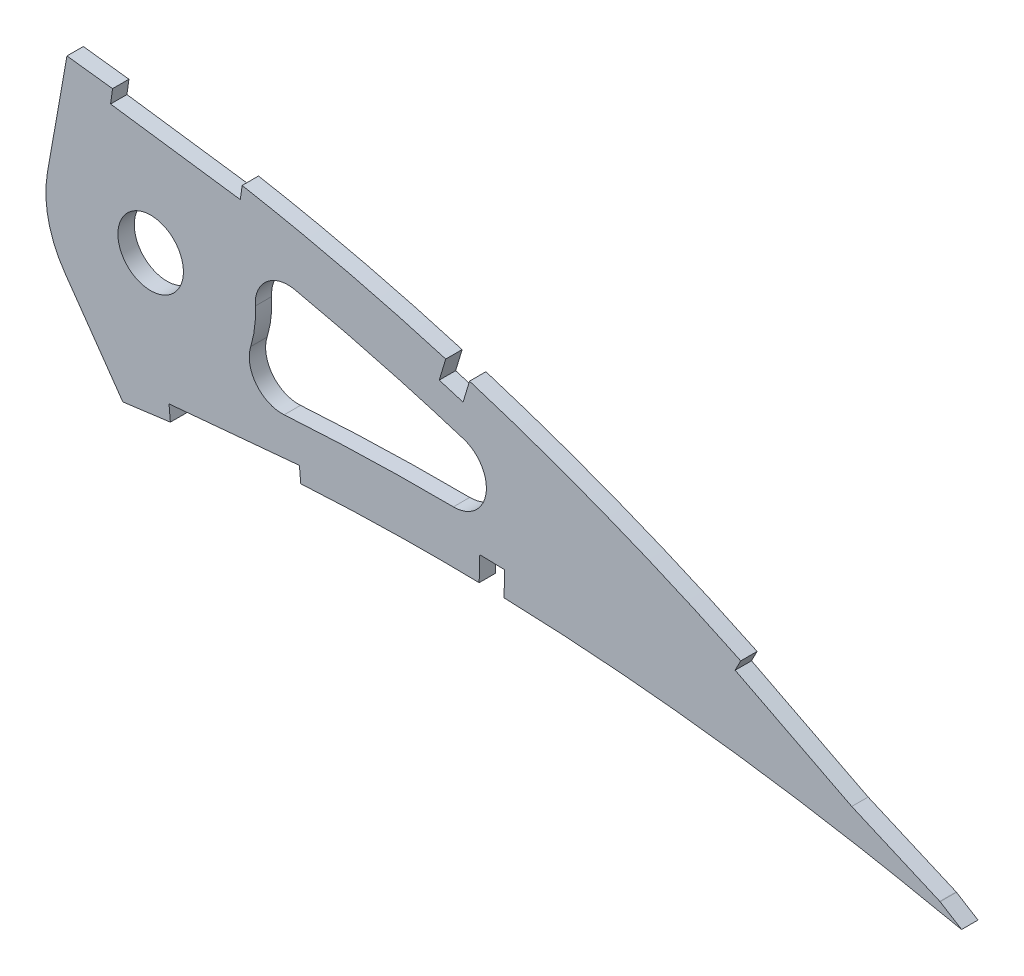
from build123d import *

# Parameters (mm, degrees)
BOSS_EXTRUDE1_DEPTH = 3.175
CUT_EXTRUDE3_DEPTH  = 4.1750001
CUT_EXTRUDE4_DEPTH  = 7.62
FILLET1_R           = 6.35


with BuildPart() as part:
    # Sketch1 → Boss-Extrude1 (new body)
    with BuildSketch(Plane.XY):
        with BuildLine():
            Line((519.580178516, -0.811051185), (524.404942797, -1.768650656))
            Line((524.404942797, -1.768650656), (520.229019484, 0.811051185))
            add(Edge.make_bspline(
                [(520.229019484, 0.811051185), (520.189166605, 0.835670541), (520.029909792, 0.934052399), (519.671075297, 1.154156729), (519.073541109, 1.52075127), (518.237045599, 2.031290225), (517.162238007, 2.684417324), (515.848577801, 3.475559373), (514.296885216, 4.402146321), (512.507535633, 5.459795421), (510.480712337, 6.64355473), (508.21718701, 7.948628257), (505.717156954, 9.367627965), (502.981590452, 10.894755239), (500.011426026, 12.522747531), (496.807225449, 14.244251548), (493.37013628, 16.050511122), (489.701477824, 17.933756977), (485.801919013, 19.88358962), (481.673298347, 21.891894303), (477.316991217, 23.948657398), (472.734484625, 26.042905917), (467.928411224, 28.166102482), (462.900099753, 30.30504754), (457.652415647, 32.45047346), (452.187593096, 34.590170691), (446.508867721, 36.714394111), (440.618430338, 38.809382682), (434.52068427, 40.865980983), (428.218587641, 42.870829), (421.71664718, 44.813038248), (415.018640596, 46.680016502), (408.130151416, 48.4621889), (401.05554842, 50.146576673), (393.800827801, 51.721905645), (386.37175624, 53.178690862), (378.7745642, 54.502388693), (371.03030434, 55.691966852), (363.263579962, 56.681494561), (355.512835044, 57.651994424), (347.773632806, 58.563690257), (339.939841334, 59.436765181), (332.018997168, 60.266303487), (324.018957152, 61.049711288), (315.947820171, 61.783607472), (307.813973652, 62.465839869), (299.625288266, 63.092542591), (291.390398495, 63.662750235), (283.117445562, 64.171449818), (274.815241205, 64.618259557), (266.492213302, 65.000063177), (258.157023363, 65.314229919), (249.818522106, 65.558863312), (241.485365181, 65.731619671), (233.166575282, 65.831412809), (224.870805251, 65.855515939), (216.607073574, 65.803497941), (208.384033719, 65.673572684), (200.210713382, 65.463961556), (192.095777843, 65.174273359), (184.048002143, 64.804633746), (176.076197788, 64.351947189), (168.189012741, 63.819098613), (160.39523005, 63.203849575), (152.703412853, 62.5060365), (145.121622257, 61.728568125), (137.65829938, 60.86932984), (130.321442651, 59.930766435), (123.119077117, 58.914718085), (116.059284027, 57.820631377), (109.149625996, 56.651666482), (102.397560522, 55.409019412), (95.81023125, 54.096333304), (89.394810054, 52.713950514), (83.158087983, 51.266017865), (77.106546628, 49.75505799), (71.246691254, 48.18383703), (65.58446207, 46.556125144), (60.125584795, 44.875615234), (54.876423204, 43.144153764), (49.840944503, 41.368305654), (45.025334256, 39.549331576), (40.433281375, 37.692835265), (36.070167381, 35.80135162), (31.939251719, 33.880646801), (28.045209615, 31.932907511), (24.39081638, 29.963590665), (20.979740738, 27.975715944), (17.815266227, 25.972975661), (14.898722839, 23.96044987), (12.234131686, 21.939401784), (9.822408113, 19.914938493), (7.665078309, 17.890142748), (5.765226023, 15.866409302), (4.122782784, 13.847302025), (2.739901149, 11.834419923), (1.61682102, 9.829667672), (0.75608259, 7.834501578), (0.156832386, 5.85004365), (-0.171193188, 3.879222922), (-0.252840734, 1.920459398), (-0.084154315, 0.639196632), (0, 0)],
                knots=[0, 0, 0, 0, 0.00025409, 0.001015373, 0.002283359, 0.004056577, 0.006330982, 0.009105275, 0.012374489, 0.016134023, 0.02037966, 0.025105976, 0.030306237, 0.035972206, 0.042099522, 0.048678064, 0.055701664, 0.063160184, 0.071045824, 0.079349826, 0.08806291, 0.097175757, 0.106678112, 0.116561573, 0.126814276, 0.1374283, 0.148393618, 0.15969976, 0.171338126, 0.183297699, 0.195569604, 0.208143556, 0.221011593, 0.234161831, 0.24758745, 0.261276822, 0.27522271, 0.289414144, 0.3037712, 0.317689227, 0.331784111, 0.346039677, 0.36044387, 0.374982721, 0.389640455, 0.404403317, 0.419256601, 0.434186749, 0.449177265, 0.464214782, 0.479284009, 0.49436974, 0.509457833, 0.524532346, 0.53957932, 0.554582984, 0.569529546, 0.584403417, 0.599190992, 0.613876838, 0.628447475, 0.642888675, 0.657186054, 0.671325546, 0.685294014, 0.699078147, 0.712665095, 0.726042645, 0.739197713, 0.752117586, 0.764792042, 0.777208152, 0.789355685, 0.80122396, 0.812803686, 0.824082909, 0.835054602, 0.845709571, 0.856037853, 0.866033834, 0.875688843, 0.884997719, 0.893953426, 0.902552897, 0.910789386, 0.918660734, 0.926166253, 0.933302626, 0.94007122, 0.94647478, 0.952517526, 0.958204819, 0.963546652, 0.9685566, 0.973249913, 0.977651041, 0.981787043, 0.985694226, 0.989415109, 0.993001157, 0.996508416, 1, 1, 1, 1], degree=3))
            add(Edge.make_bspline(
                [(0, 0), (0.133592971, -0.630647919), (0.401392883, -1.8948421), (1.12897029, -3.714757932), (2.091156676, -5.464224213), (3.308146123, -7.138593951), (4.771846833, -8.737409521), (6.479026026, -10.262333902), (8.42800953, -11.712547121), (10.616246406, -13.087389262), (13.040557967, -14.388319695), (15.69821927, -15.614529628), (18.58680706, -16.765635887), (21.703174164, -17.840099654), (25.043510698, -18.839557444), (28.604640883, -19.761573512), (32.382515332, -20.607436647), (36.373500457, -21.374987622), (40.573247311, -22.065006311), (44.977392966, -22.677106427), (49.581416855, -23.211670923), (54.380802091, -23.667578066), (59.370801609, -24.045808466), (64.546441805, -24.346612989), (69.902698778, -24.570945614), (75.434441794, -24.717953346), (81.136253147, -24.789928223), (87.002979994, -24.787950681), (93.028883282, -24.711491768), (99.208815464, -24.564775433), (105.536846201, -24.346872236), (112.007262561, -24.060419153), (118.614228145, -23.708298892), (125.351817225, -23.291705179), (132.214100493, -22.812484346), (139.195119589, -22.274479418), (146.288532921, -21.679032497), (153.488154076, -21.029614162), (160.787609185, -20.329475604), (168.180591644, -19.580832593), (175.660575836, -18.787206853), (183.220899465, -17.951170059), (190.855131019, -17.077182461), (198.556296664, -16.166825422), (206.317884213, -15.225296547), (214.132591981, -14.254394805), (221.993885293, -13.257859815), (229.894693671, -12.240383742), (237.827620604, -11.201850487), (245.785993956, -10.149659277), (253.762138918, -9.082943465), (261.749112783, -8.007189221), (269.739522148, -6.925740253), (277.725584215, -5.838929488), (285.70027901, -4.751260828), (293.656208576, -3.665720235), (301.585579958, -2.582406874), (309.481219182, -1.506705212), (317.335175518, -0.438483792), (325.140206955, 0.620091626), (332.888833934, 1.665861231), (340.573746099, 2.697505345), (348.187015915, 3.714371056), (355.720983847, 4.716840325), (363.055280122, 5.674485749), (370.170740115, 6.638302095), (377.091341637, 7.428417974), (383.925772848, 8.102810237), (390.681133097, 8.655718896), (397.349310673, 9.095098533), (403.922665289, 9.424088714), (410.393362863, 9.647282626), (416.753229966, 9.771301523), (422.994322965, 9.799292754), (429.108122993, 9.740182902), (435.086678505, 9.598736647), (440.921645401, 9.381302955), (446.604883368, 9.095217537), (452.128319892, 8.748279397), (457.483662622, 8.34560601), (462.663449177, 7.896598156), (467.65968785, 7.407828642), (472.464706853, 6.884881883), (477.071494939, 6.338715544), (481.472678479, 5.77292572), (485.661637464, 5.196810252), (489.631628754, 4.616207627), (493.376364947, 4.038530197), (496.889962423, 3.469289139), (500.16674573, 2.91603967), (503.201581909, 2.38395084), (505.989204715, 1.878219093), (508.525746868, 1.40522509), (510.806198597, 0.967318665), (512.827510034, 0.571716412), (514.585922757, 0.220164109), (516.078859088, -0.082385429), (517.303711765, -0.334738039), (518.258620558, -0.532751237), (518.941699265, -0.676741413), (519.352209069, -0.762422848), (519.534603778, -0.801329602), (519.580178516, -0.811051185)],
                knots=[0, 0, 0, 0, 0.003638255, 0.007293231, 0.011028136, 0.014901081, 0.018963272, 0.023258475, 0.027820626, 0.032679082, 0.03785316, 0.043361875, 0.049214679, 0.055422346, 0.061988786, 0.068918036, 0.076211157, 0.083868392, 0.091887411, 0.100265912, 0.108999867, 0.118084529, 0.127514843, 0.13728527, 0.147387917, 0.157816481, 0.168563473, 0.179619128, 0.190977373, 0.202626974, 0.214560478, 0.226767249, 0.239236417, 0.251959004, 0.264923894, 0.278119703, 0.291536035, 0.30516028, 0.318980685, 0.332985499, 0.34716279, 0.361498603, 0.375980747, 0.390597192, 0.405332593, 0.420174823, 0.435109533, 0.450124276, 0.465203068, 0.480333154, 0.495500583, 0.510689775, 0.525887334, 0.541078314, 0.556247233, 0.571381784, 0.586466041, 0.601484516, 0.616424329, 0.631269422, 0.646006524, 0.660620684, 0.675098188, 0.689422858, 0.703581825, 0.716907564, 0.730009274, 0.742952128, 0.755725558, 0.768319952, 0.780724337, 0.792926529, 0.804916041, 0.816679084, 0.828203524, 0.8394749, 0.850481359, 0.861207697, 0.871639326, 0.881763414, 0.891563605, 0.901027364, 0.910138977, 0.918883976, 0.927249278, 0.935221104, 0.942784739, 0.949928188, 0.956638464, 0.962904203, 0.968712287, 0.974054485, 0.978918432, 0.983297219, 0.987180246, 0.990560674, 0.993433357, 0.995790625, 0.997629587, 0.998945816, 0.999736592, 1, 1, 1, 1], degree=3))
        make_face()
    extrude(amount=BOSS_EXTRUDE1_DEPTH)

    # Sketch4 → Cut-Extrude3 (cut, through all)
    with BuildSketch(Plane(origin=(0, 0, 0), x_dir=(-1, 0, 0), z_dir=(0, 0, -1))):
        with BuildLine():
            Line((-349.142459993, 48.169188001), (-347.130907312, 36.761105856))
            ThreePointArc((-347.130907312, 36.761105856), (-346.899524588, 35.003579579), (-346.822200854, 33.232574886))
            ThreePointArc((-346.822200854, 33.232574886), (-347.762672414, 27.12223304), (-350.497031314, 21.577501699))
            Line((-350.497031314, 21.577501699), (-355.179611663, 14.890083907))
            add(Edge.make_bspline(
                [(-355.179611663, 14.890083907), (-354.634768183, 14.81838126), (-351.343111064, 14.384733115), (-345.317068282, 13.581422906), (-334.359007699, 12.116770486), (-315.178957353, 9.528809507), (-287.808238346, 5.789020446), (-254.983546479, 1.313075622), (-222.189540662, -3.034811338), (-189.410638648, -7.095853132), (-156.653979445, -10.650756055), (-129.381299848, -12.944898136), (-107.608324737, -14.148463497), (-91.320521139, -14.652053641), (-75.107437099, -14.647466184), (-61.710842675, -14.089664127), (-51.134134813, -13.189629084), (-43.306667964, -12.239557455), (-35.641142462, -10.958898329), (-28.237034853, -9.263609663), (-21.289211903, -7.058302801), (-16.203229259, -4.686643315), (-13.046062847, -2.547825054), (-11.605646483, -1.201001207), (-10.835951724, -0.222672899), (-10.520186588, 0.293626308), (-10.288606614, 0.769486043), (-10.205494123, 0.982386522), (-10.178508929, 1.064293938), (-10.15770337, 1.134911906), (-10.110488282, 1.322521107), (-10.064288932, 1.524878966), (-10.035416174, 1.656454651), (-10.021983668, 1.718504447)],
                knots=[0.309141937, 0.309141937, 0.309141937, 0.309141937, 0.312240805, 0.327852845, 0.343464885, 0.374688966, 0.437137127, 0.499585288, 0.562033448, 0.624481609, 0.68692977, 0.749377931, 0.780602012, 0.811826092, 0.843050173, 0.874274253, 0.889886293, 0.905498334, 0.921110374, 0.936722414, 0.952334454, 0.967946495, 0.975752515, 0.983558535, 0.987461545, 0.991364555, 0.99331606, 0.995267565, 0.996243318, 0.99721907, 0.998194823, 0.998682699, 0.999170575, 0.999170575, 0.999170575, 0.999170575], degree=3))
            add(Edge.make_bspline(
                [(-10.021983668, 1.718504447), (-10.013687856, 1.783768627), (-9.996445529, 1.922731887), (-9.972174442, 2.13380764), (-9.954758577, 2.326720127), (-9.95209276, 2.384964033), (-9.950305509, 2.48525297), (-9.961308657, 2.734439136), (-10.012167255, 3.144193433), (-10.083924075, 3.510172621), (-10.222387191, 4.033107903), (-10.617125097, 5.11754818), (-11.618419928, 6.925188316), (-14.102556964, 10.090723207), (-18.425636817, 14.053423759), (-24.652613537, 18.402785053), (-31.49228206, 22.339174543), (-38.727193503, 25.901322004), (-46.234469632, 29.135461005), (-56.507441507, 33.059973808), (-69.720706242, 37.323053539), (-85.944850414, 41.597783381), (-102.419374763, 45.156825801), (-124.627374805, 49.072607453), (-152.703767215, 52.587446016), (-186.671940606, 55.005427433), (-220.783980102, 55.888644379), (-254.954152119, 55.438562708), (-289.123377617, 53.797708511), (-317.566439881, 51.530591277), (-337.432329226, 49.501787715), (-346.070123739, 48.528859346), (-349.021979224, 48.183312846), (-349.142459993, 48.169188001)],
                knots=[0.000796283, 0.000796283, 0.000796283, 0.000796283, 0.001284176, 0.001772068, 0.002747853, 0.003723638, 0.004699423, 0.006650992, 0.008602562, 0.010554132, 0.012505702, 0.016408841, 0.02421512, 0.032021399, 0.047633957, 0.063246516, 0.078859074, 0.094471632, 0.11008419, 0.125696748, 0.156921864, 0.18814698, 0.219372096, 0.250597212, 0.313047445, 0.375497677, 0.437947909, 0.500398142, 0.562848374, 0.625298606, 0.656523722, 0.67213628, 0.672800692, 0.672800692, 0.672800692, 0.672800692], degree=3))
        make_face()
        with BuildLine():
            ThreePointArc((-360.792200854, 33.232574886), (-367.142200854, 39.582574886), (-373.492200854, 33.232574886))
            ThreePointArc((-373.492200854, 33.232574886), (-367.142200854, 26.882574886), (-360.792200854, 33.232574886))
        make_face()
        with BuildLine():
            Line((-350.909730833, 58.191878985), (-349.142459993, 48.169188001))
            add(Edge.make_bspline(
                [(-10.021983668, 1.718504447), (-10.013687856, 1.783768627), (-9.996445529, 1.922731887), (-9.972174442, 2.13380764), (-9.954758577, 2.326720127), (-9.95209276, 2.384964033), (-9.950305509, 2.48525297), (-9.961308657, 2.734439136), (-10.012167255, 3.144193433), (-10.083924075, 3.510172621), (-10.222387191, 4.033107903), (-10.617125097, 5.11754818), (-11.618419928, 6.925188316), (-14.102556964, 10.090723207), (-18.425636817, 14.053423759), (-24.652613537, 18.402785053), (-31.49228206, 22.339174543), (-38.727193503, 25.901322004), (-46.234469632, 29.135461005), (-56.507441507, 33.059973808), (-69.720706242, 37.323053539), (-85.944850414, 41.597783381), (-102.419374763, 45.156825801), (-124.627374805, 49.072607453), (-152.703767215, 52.587446016), (-186.671940606, 55.005427433), (-220.783980102, 55.888644379), (-254.954152119, 55.438562708), (-289.123377617, 53.797708511), (-317.566439881, 51.530591277), (-337.432329226, 49.501787715), (-346.070123739, 48.528859346), (-349.021979224, 48.183312846), (-349.142459993, 48.169188001)],
                knots=[0.000796283, 0.000796283, 0.000796283, 0.000796283, 0.001284176, 0.001772068, 0.002747853, 0.003723638, 0.004699423, 0.006650992, 0.008602562, 0.010554132, 0.012505702, 0.016408841, 0.02421512, 0.032021399, 0.047633957, 0.063246516, 0.078859074, 0.094471632, 0.11008419, 0.125696748, 0.156921864, 0.18814698, 0.219372096, 0.250597212, 0.313047445, 0.375497677, 0.437947909, 0.500398142, 0.562848374, 0.625298606, 0.656523722, 0.67213628, 0.672800692, 0.672800692, 0.672800692, 0.672800692], degree=3))
            add(Edge.make_bspline(
                [(-355.179611663, 14.890083907), (-354.634768183, 14.81838126), (-351.343111064, 14.384733115), (-345.317068282, 13.581422906), (-334.359007699, 12.116770486), (-315.178957353, 9.528809507), (-287.808238346, 5.789020446), (-254.983546479, 1.313075622), (-222.189540662, -3.034811338), (-189.410638648, -7.095853132), (-156.653979445, -10.650756055), (-129.381299848, -12.944898136), (-107.608324737, -14.148463497), (-91.320521139, -14.652053641), (-75.107437099, -14.647466184), (-61.710842675, -14.089664127), (-51.134134813, -13.189629084), (-43.306667964, -12.239557455), (-35.641142462, -10.958898329), (-28.237034853, -9.263609663), (-21.289211903, -7.058302801), (-16.203229259, -4.686643315), (-13.046062847, -2.547825054), (-11.605646483, -1.201001207), (-10.835951724, -0.222672899), (-10.520186588, 0.293626308), (-10.288606614, 0.769486043), (-10.205494123, 0.982386522), (-10.178508929, 1.064293938), (-10.15770337, 1.134911906), (-10.110488282, 1.322521107), (-10.064288932, 1.524878966), (-10.035416174, 1.656454651), (-10.021983668, 1.718504447)],
                knots=[0.309141937, 0.309141937, 0.309141937, 0.309141937, 0.312240805, 0.327852845, 0.343464885, 0.374688966, 0.437137127, 0.499585288, 0.562033448, 0.624481609, 0.68692977, 0.749377931, 0.780602012, 0.811826092, 0.843050173, 0.874274253, 0.889886293, 0.905498334, 0.921110374, 0.936722414, 0.952334454, 0.967946495, 0.975752515, 0.983558535, 0.987461545, 0.991364555, 0.99331606, 0.995267565, 0.996243318, 0.99721907, 0.998194823, 0.998682699, 0.999170575, 0.999170575, 0.999170575, 0.999170575], degree=3))
            Line((-355.179611663, 14.890083907), (-361.749554482, 5.507233166))
            add(Edge.make_bspline(
                [(-361.749554482, 5.507233166), (-359.750002253, 5.242796176), (-355.23730571, 4.652482144), (-348.187015915, 3.714371056), (-340.573746099, 2.697505345), (-332.888833934, 1.665861231), (-325.140206955, 0.620091626), (-317.335175518, -0.438483792), (-309.481219182, -1.506705212), (-301.585579958, -2.582406874), (-293.656208576, -3.665720235), (-285.70027901, -4.751260828), (-277.725584215, -5.838929488), (-269.739522148, -6.925740253), (-261.749112783, -8.007189221), (-253.762138918, -9.082943465), (-245.785993956, -10.149659277), (-237.827620604, -11.201850487), (-229.894693671, -12.240383742), (-221.993885293, -13.257859815), (-214.132591981, -14.254394805), (-206.317884213, -15.225296547), (-198.556296664, -16.166825422), (-190.855131019, -17.077182461), (-183.220899465, -17.951170059), (-175.660575836, -18.787206853), (-168.180591644, -19.580832593), (-160.787609185, -20.329475604), (-153.488154076, -21.029614162), (-146.288532921, -21.679032497), (-139.195119589, -22.274479418), (-132.214100493, -22.812484346), (-125.351817225, -23.291705179), (-118.614228145, -23.708298892), (-112.007262561, -24.060419153), (-105.536846201, -24.346872236), (-99.208815464, -24.564775433), (-93.028883282, -24.711491768), (-87.002979994, -24.787950681), (-81.136253147, -24.789928223), (-75.434441794, -24.717953346), (-69.902698778, -24.570945614), (-64.546441805, -24.346612989), (-59.370801609, -24.045808466), (-54.380802091, -23.667578066), (-49.581416855, -23.211670923), (-44.977392966, -22.677106427), (-40.573247311, -22.065006311), (-36.373500457, -21.374987622), (-32.382515332, -20.607436647), (-28.604640883, -19.761573512), (-25.043510698, -18.839557444), (-21.703174164, -17.840099654), (-18.58680706, -16.765635887), (-15.69821927, -15.614529628), (-13.040557967, -14.388319695), (-10.616246406, -13.087389262), (-8.42800953, -11.712547121), (-6.479026026, -10.262333902), (-4.771846833, -8.737409521), (-3.308146123, -7.138593951), (-2.091156676, -5.464224213), (-1.12897029, -3.714757932), (-0.401392883, -1.8948421), (-0.133592971, -0.630647919), (0, 0)],
                knots=[0.299176266, 0.299176266, 0.299176266, 0.299176266, 0.310577142, 0.324901812, 0.339379316, 0.353993476, 0.368730578, 0.383575671, 0.398515484, 0.413533959, 0.428618216, 0.443752767, 0.458921686, 0.474112666, 0.489310225, 0.504499417, 0.519666846, 0.534796932, 0.549875724, 0.564890467, 0.579825177, 0.594667407, 0.609402808, 0.624019253, 0.638501397, 0.65283721, 0.667014501, 0.681019315, 0.69483972, 0.708463965, 0.721880297, 0.735076106, 0.748040996, 0.760763583, 0.773232751, 0.785439522, 0.797373026, 0.809022627, 0.820380872, 0.831436527, 0.842183519, 0.852612083, 0.86271473, 0.872485157, 0.881915471, 0.891000133, 0.899734088, 0.908112589, 0.916131608, 0.923788843, 0.931081964, 0.938011214, 0.944577654, 0.950785321, 0.956638125, 0.96214684, 0.967320918, 0.972179374, 0.976741525, 0.981036728, 0.985098919, 0.988971864, 0.992706769, 0.996361745, 1, 1, 1, 1], degree=3))
            add(Edge.make_bspline(
                [(0, 0), (0.084154315, 0.639196632), (0.252840734, 1.920459398), (0.171193188, 3.879222922), (-0.156832386, 5.85004365), (-0.75608259, 7.834501578), (-1.61682102, 9.829667672), (-2.739901149, 11.834419923), (-4.122782784, 13.847302025), (-5.765226023, 15.866409302), (-7.665078309, 17.890142748), (-9.822408113, 19.914938493), (-12.234131686, 21.939401784), (-14.898722839, 23.96044987), (-17.815266227, 25.972975661), (-20.979740738, 27.975715944), (-24.39081638, 29.963590665), (-28.045209615, 31.932907511), (-31.939251719, 33.880646801), (-36.070167381, 35.80135162), (-40.433281375, 37.692835265), (-45.025334256, 39.549331576), (-49.840944503, 41.368305654), (-54.876423204, 43.144153764), (-60.125584795, 44.875615234), (-65.58446207, 46.556125144), (-71.246691254, 48.18383703), (-77.106546628, 49.75505799), (-83.158087983, 51.266017865), (-89.394810054, 52.713950514), (-95.81023125, 54.096333304), (-102.397560522, 55.409019412), (-109.149625996, 56.651666482), (-116.059284027, 57.820631377), (-123.119077117, 58.914718085), (-130.321442651, 59.930766435), (-137.65829938, 60.86932984), (-145.121622257, 61.728568125), (-152.703412853, 62.5060365), (-160.39523005, 63.203849575), (-168.189012741, 63.819098613), (-176.076197788, 64.351947189), (-184.048002143, 64.804633746), (-192.095777843, 65.174273359), (-200.210713382, 65.463961556), (-208.384033719, 65.673572684), (-216.607073574, 65.803497941), (-224.870805251, 65.855515939), (-233.166575282, 65.831412809), (-241.485365181, 65.731619671), (-249.818522106, 65.558863312), (-258.157023363, 65.314229919), (-266.492213302, 65.000063177), (-274.815241205, 64.618259557), (-283.117445562, 64.171449818), (-291.390398495, 63.662750235), (-299.625288266, 63.092542591), (-307.813973652, 62.465839869), (-315.947820171, 61.783607472), (-324.018957152, 61.049711288), (-332.018997168, 60.266303487), (-339.939841334, 59.436765181), (-346.227461312, 58.736010846), (-349.87402552, 58.313335631), (-350.909730833, 58.191878985)],
                knots=[0, 0, 0, 0, 0.003491584, 0.006998843, 0.010584891, 0.014305774, 0.018212957, 0.022348959, 0.026750087, 0.0314434, 0.036453348, 0.041795181, 0.047482474, 0.05352522, 0.05992878, 0.066697374, 0.073833747, 0.081339266, 0.089210614, 0.097447103, 0.106046574, 0.115002281, 0.124311157, 0.133966166, 0.143962147, 0.154290429, 0.164945398, 0.175917091, 0.187196314, 0.19877604, 0.210644315, 0.222791848, 0.235207958, 0.247882414, 0.260802287, 0.273957355, 0.287334905, 0.300921853, 0.314705986, 0.328674454, 0.342813946, 0.357111325, 0.371552525, 0.386123162, 0.400809008, 0.415596583, 0.430470454, 0.445417016, 0.46042068, 0.475467654, 0.490542167, 0.50563026, 0.520715991, 0.535785218, 0.550822735, 0.565813251, 0.580743399, 0.595596683, 0.610359545, 0.625017279, 0.63955613, 0.653960323, 0.668215889, 0.673872202, 0.673872202, 0.673872202, 0.673872202], degree=3))
        make_face()
        with BuildLine():
            ThreePointArc((-387.462200854, 33.232574886), (-386.814379612, 38.322543737), (-384.912222221, 43.087966334))
            add(Edge.make_bspline(
                [(-384.912222221, 43.087966334), (-386.818824475, 42.732614345), (-394.210424123, 41.294453801), (-407.028210468, 38.374212868), (-428.620355258, 32.39115288), (-448.413992243, 25.407269546), (-462.57734912, 19.420041956), (-466.382547126, 17.738579891)],
                knots=[0.739380826, 0.739380826, 0.739380826, 0.739380826, 0.750199071, 0.781424187, 0.812649303, 0.875099535, 0.898258577, 0.898258577, 0.898258577, 0.898258577], degree=3))
            add(Edge.make_bspline(
                [(-466.382547126, 17.738579891), (-462.513007229, 18.118917697), (-447.384629134, 19.418402411), (-426.536653446, 20.177211731), (-403.909109388, 19.686350489), (-390.476664545, 18.867911853), (-382.696670013, 18.178863487), (-380.561422835, 17.973909105)],
                knots=[0.103390506, 0.103390506, 0.103390506, 0.103390506, 0.124896322, 0.187344483, 0.218568563, 0.249792644, 0.26163416, 0.26163416, 0.26163416, 0.26163416], degree=3))
            ThreePointArc((-380.561422835, 17.973909105), (-385.656803073, 24.859289708), (-387.462200854, 33.232574886))
        make_face()
    extrude(amount=-CUT_EXTRUDE3_DEPTH, mode=Mode.SUBTRACT)

    # Sketch5 → Cut-Extrude4 (cut)
    with BuildSketch(Plane.XY.offset(3.175)):
        Polygon((384.961328648, 54.016498288), (359.803806164, 57.490736253), (359.369526419, 54.346045943), (384.527048903, 50.871807978), align=None)
        Polygon((395.984366342, 11.965923207), (370.698815929, 9.653682873), (370.98784597, 6.492989071), (396.273396384, 8.805229405), align=None)
        Polygon((429.117858019, 43.070336902), (424.499319283, 44.464099147), (423.105557039, 39.845560411), (427.724095775, 38.451798166), align=None)
        Polygon((435.786991484, 14.341315593), (430.963938334, 14.459159398), (430.846094529, 9.636106247), (435.66914768, 9.518262443), align=None)
        Polygon((504.452510222, 11.115204058), (481.935027394, 22.642294806), (480.48827192, 19.816144458), (503.097474702, 8.242100672), (526.404447181, -1.854547191), (527.666528163, 1.058824369), align=None)
    extrude(amount=-CUT_EXTRUDE4_DEPTH, mode=Mode.SUBTRACT)

    # Fillet1
    fillet1_edges = [part.edges().sort_by_distance(p)[0] for p in [
        (466.382547126, 17.738579891, 1.5875),
        (380.561422835, 17.973909105, 1.5875),
        (384.912222221, 43.087966334, 1.5875),
    ]]
    fillet(fillet1_edges, radius=FILLET1_R)


solid = part.part
